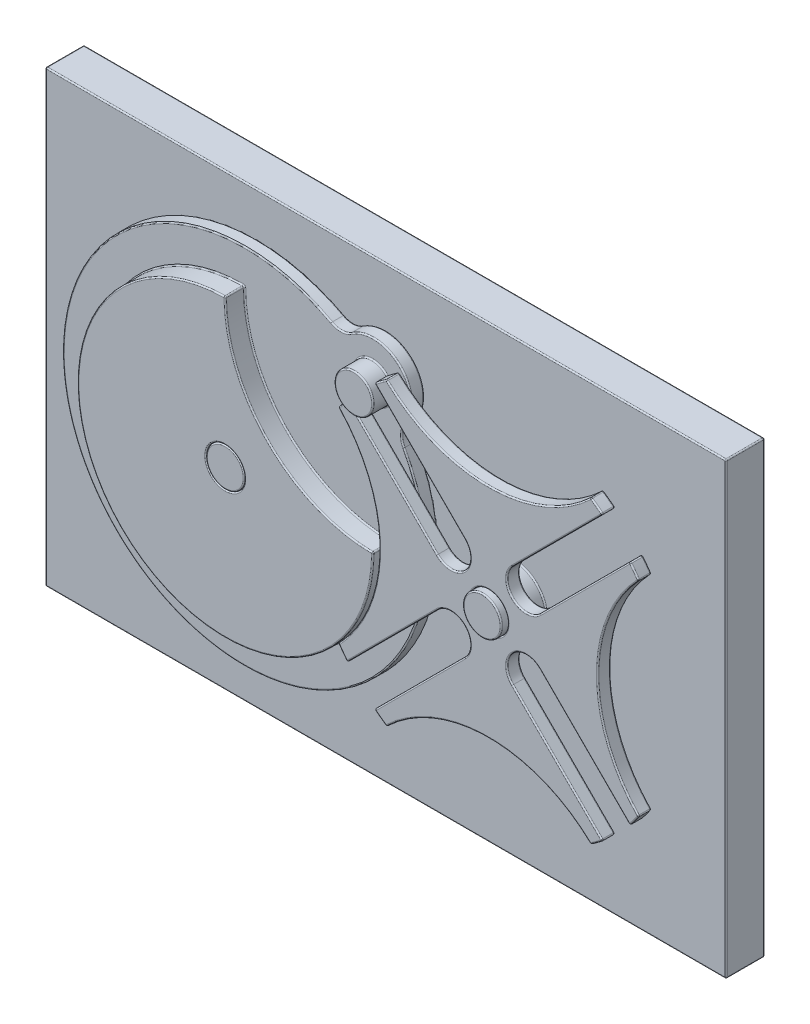
from build123d import *

# Parameters (mm, degrees)
BOSS_EXTRUDE2_DEPTH     = 10
BOSS_EXTRUDE3_DEPTH     = 10
SKETCH5_R               = 15
BOSS_EXTRUDE4_DEPTH     = 15
SKETCH6_R               = 15
CUT_EXTRUDE1_DEPTH      = 16
CUT_EXTRUDE1_DEPTH_BACK = 11
SKETCH7_W               = 530
SKETCH7_H               = 350
BOSS_EXTRUDE9_DEPTH     = 30
SKETCH8_R               = 15
BOSS_EXTRUDE10_DEPTH    = 25
SKETCH9_R               = 25
BOSS_EXTRUDE11_DEPTH    = 10
FILLET3_R               = 1
FILLET4_R               = 1
FILLET5_R               = 1


with BuildPart() as part:
    # Sketch3 → Boss-Extrude2 (new body)
    with BuildSketch(Plane.XY):
        with BuildLine():
            Line((60.104076401, 18.682720164), (-10.042510725, 88.829307289))
            ThreePointArc((-10.042510725, 88.829307289), (-13.585135714, 84.252103504), (-16.9375, 79.53377329))
            ThreePointArc((-16.9375, 79.53377329), (15, 0), (-16.9375, -79.53377329))
            ThreePointArc((-16.9375, -79.53377329), (-13.585135714, -84.252103504), (-10.042510725, -88.829307289))
            Line((-10.042510725, -88.829307289), (60.104076401, -18.682720164))
            ThreePointArc((60.104076401, -18.682720164), (81.317279836, -18.682720164), (81.317279836, -39.895923599))
            Line((81.317279836, -39.895923599), (11.170692711, -110.042510725))
            ThreePointArc((11.170692711, -110.042510725), (15.747896496, -113.585135714), (20.46622671, -116.9375))
            ThreePointArc((20.46622671, -116.9375), (100, -85), (179.53377329, -116.9375))
            ThreePointArc((179.53377329, -116.9375), (184.252103504, -113.585135714), (188.829307289, -110.042510725))
            Line((188.829307289, -110.042510725), (118.682720164, -39.895923599))
            ThreePointArc((118.682720164, -39.895923599), (118.682720164, -18.682720164), (139.895923599, -18.682720164))
            Line((139.895923599, -18.682720164), (210.042510725, -88.829307289))
            ThreePointArc((210.042510725, -88.829307289), (213.585135714, -84.252103504), (216.9375, -79.53377329))
            ThreePointArc((216.9375, -79.53377329), (185, 0), (216.9375, 79.53377329))
            ThreePointArc((216.9375, 79.53377329), (213.585135714, 84.252103504), (210.042510725, 88.829307289))
            Line((210.042510725, 88.829307289), (139.895923599, 18.682720164))
            ThreePointArc((139.895923599, 18.682720164), (118.682720164, 18.682720164), (118.682720164, 39.895923599))
            Line((118.682720164, 39.895923599), (188.829307289, 110.042510725))
            ThreePointArc((188.829307289, 110.042510725), (184.252103504, 113.585135714), (179.53377329, 116.9375))
            ThreePointArc((179.53377329, 116.9375), (100, 85), (20.46622671, 116.9375))
            ThreePointArc((20.46622671, 116.9375), (15.747896496, 113.585135714), (11.170692711, 110.042510725))
            Line((11.170692711, 110.042510725), (81.317279836, 39.895923599))
            ThreePointArc((81.317279836, 39.895923599), (81.317279836, 18.682720164), (60.104076401, 18.682720164))
        make_face()
    extrude(amount=BOSS_EXTRUDE2_DEPTH)


with BuildPart() as body_2:
    # Sketch4 → Boss-Extrude3 (new body)
    with BuildSketch(Plane.XY):
        with BuildLine():
            ThreePointArc((-32.302179606, 124.165233113), (-200, -100), (24.165233113, 67.697820394))
            ThreePointArc((24.165233113, 67.697820394), (22.351200484, 75.576402155), (24.889963241, 83.252172383))
            ThreePointArc((24.889963241, 83.252172383), (21.213203436, 121.213203436), (-16.747827617, 124.889963241))
            ThreePointArc((-16.747827617, 124.889963241), (-24.423597845, 122.351200484), (-32.302179606, 124.165233113))
        make_face()
    extrude(amount=-BOSS_EXTRUDE3_DEPTH)

    # Sketch5 → Boss-Extrude4 (add)
    with BuildSketch(Plane.XY):
        with Locations((0, 100)):
            Circle(SKETCH5_R)
        with BuildLine():
            ThreePointArc((-100, 115), (-181.317279836, -81.317279836), (15, 0))
            ThreePointArc((15, 0), (-66.317279836, 33.682720164), (-100, 115))
        make_face()
    extrude(amount=BOSS_EXTRUDE4_DEPTH)


with BuildPart() as cut_extrude1_tool:
    # Sketch6 → Cut-Extrude1 (new body, two sides)
    with BuildSketch(Plane.XY) as cut_extrude1_sk:
        with Locations((-100, 0)):
            Circle(SKETCH6_R)
        with Locations((100, 0)):
            Circle(SKETCH6_R)
    extrude(amount=CUT_EXTRUDE1_DEPTH)
    extrude(cut_extrude1_sk.sketch, amount=-CUT_EXTRUDE1_DEPTH_BACK)


with BuildPart() as part_1:
    add(part.part)

    # Cut-Extrude1: cut by cut_extrude1_tool
    add(cut_extrude1_tool.part, mode=Mode.SUBTRACT)

    # Fillet3
    fillet3_edges = [part_1.edges().sort_by_distance(p)[0] for p in [
        (-13.585135714, 84.252103504, 10),
        (15, 0, 10),
        (-13.585135714, -84.252103504, 10),
        (25.030782838, -53.756013726, 10),
        (46.243986274, 74.969217162, 0),
        (15.747896496, 113.585135714, 0),
        (100, 85, 0),
        (184.252103504, 113.585135714, 0),
        (81.317279836, -18.682720164, 10),
        (153.756013726, 74.969217162, 0),
        (118.682720164, 18.682720164, 0),
        (174.969217162, 53.756013726, 0),
        (213.585135714, 84.252103504, 0),
        (185, 0, 0),
        (213.585135714, -84.252103504, 0),
        (174.969217162, -53.756013726, 0),
        (118.682720164, -18.682720164, 0),
        (46.243986274, -74.969217162, 10),
        (153.756013726, -74.969217162, 0),
        (184.252103504, -113.585135714, 0),
        (100, -85, 0),
        (15.747896496, -113.585135714, 0),
        (46.243986274, -74.969217162, 0),
        (81.317279836, -18.682720164, 0),
        (25.030782838, -53.756013726, 0),
        (15.747896496, -113.585135714, 10),
        (-13.585135714, -84.252103504, 0),
        (15, 0, 0),
        (-13.585135714, 84.252103504, 0),
        (25.030782838, 53.756013726, 0),
        (81.317279836, 18.682720164, 0),
        (100, -85, 10),
        (184.252103504, -113.585135714, 10),
        (153.756013726, -74.969217162, 10),
        (11.170692711, 110.042510725, 5),
        (20.46622671, 116.9375, 5),
        (179.53377329, 116.9375, 5),
        (188.829307289, 110.042510725, 5),
        (210.042510725, 88.829307289, 5),
        (216.9375, 79.53377329, 5),
        (216.9375, -79.53377329, 5),
        (210.042510725, -88.829307289, 5),
        (188.829307289, -110.042510725, 5),
        (179.53377329, -116.9375, 5),
        (20.46622671, -116.9375, 5),
        (11.170692711, -110.042510725, 5),
        (-10.042510725, -88.829307289, 5),
        (-16.9375, -79.53377329, 5),
        (-16.9375, 79.53377329, 5),
        (-10.042510725, 88.829307289, 5),
        (81.317279836, 18.682720164, 10),
        (118.682720164, -18.682720164, 10),
        (174.969217162, -53.756013726, 10),
        (213.585135714, -84.252103504, 10),
        (185, 0, 10),
        (213.585135714, 84.252103504, 10),
        (174.969217162, 53.756013726, 10),
        (118.682720164, 18.682720164, 10),
        (153.756013726, 74.969217162, 10),
        (184.252103504, 113.585135714, 10),
        (85, 0, 10),
        (85, 0, 0),
        (100, 85, 10),
        (25.030782838, 53.756013726, 10),
        (15.747896496, 113.585135714, 10),
        (46.243986274, 74.969217162, 10),
    ]]
    fillet(fillet3_edges, radius=FILLET3_R)


with BuildPart() as body_2_1:
    add(body_2.part)

    # Cut-Extrude1: cut by cut_extrude1_tool
    add(cut_extrude1_tool.part, mode=Mode.SUBTRACT)

    # Fillet4
    fillet4_edges = [body_2_1.edges().sort_by_distance(p)[0] for p in [
        (-24.423597845, 122.351200484, -10),
        (-200, -100, -10),
        (-15, 100, 0),
        (-15, 100, 15),
        (-66.317279836, 33.682720164, 0),
        (15, 0, 7.5),
        (-181.317279836, -81.317279836, 0),
        (-100, 115, 7.5),
        (-66.317279836, 33.682720164, 15),
        (-181.317279836, -81.317279836, 15),
        (-115, 0, -10),
        (-115, 0, 15),
        (22.351200484, 75.576402155, -10),
        (-200, -100, 0),
        (-24.423597845, 122.351200484, 0),
        (21.213203436, 121.213203436, 0),
        (22.351200484, 75.576402155, 0),
        (21.213203436, 121.213203436, -10),
    ]]
    fillet(fillet4_edges, radius=FILLET4_R)


with BuildPart() as body_3:
    # Sketch7 → Boss-Extrude9 (new body)
    with BuildSketch(Plane.XY.offset(-10)):
        Rectangle(SKETCH7_W, SKETCH7_H)
    extrude(amount=-BOSS_EXTRUDE9_DEPTH)

    # Sketch8 → Boss-Extrude10 (add)
    with BuildSketch(Plane.XY.offset(-10)):
        with Locations((-100, 0)):
            Circle(SKETCH8_R)
        with Locations((100, 0)):
            Circle(SKETCH8_R)
    extrude(amount=BOSS_EXTRUDE10_DEPTH)

    # Sketch9 → Boss-Extrude11 (add)
    with BuildSketch(Plane.XY.offset(-10)):
        with Locations((100, 0)):
            Circle(SKETCH9_R)
    extrude(amount=BOSS_EXTRUDE11_DEPTH)

    # Fillet5
    fillet5_edges = [body_3.edges().sort_by_distance(p)[0] for p in [
        (-265, 0, -40),
        (0, -175, -40),
        (-115, 0, 15),
        (-115, 0, -10),
        (85, 0, 15),
        (75, 0, -10),
        (265, 0, -40),
        (0, -175, -10),
        (-265, 0, -10),
        (0, 175, -10),
        (265, 0, -10),
        (0, 175, -40),
        (265, -175, -25),
        (-265, -175, -25),
        (-265, 175, -25),
        (265, 175, -25),
    ]]
    fillet(fillet5_edges, radius=FILLET5_R)


solid = Compound([part_1.part, body_2_1.part, body_3.part])
